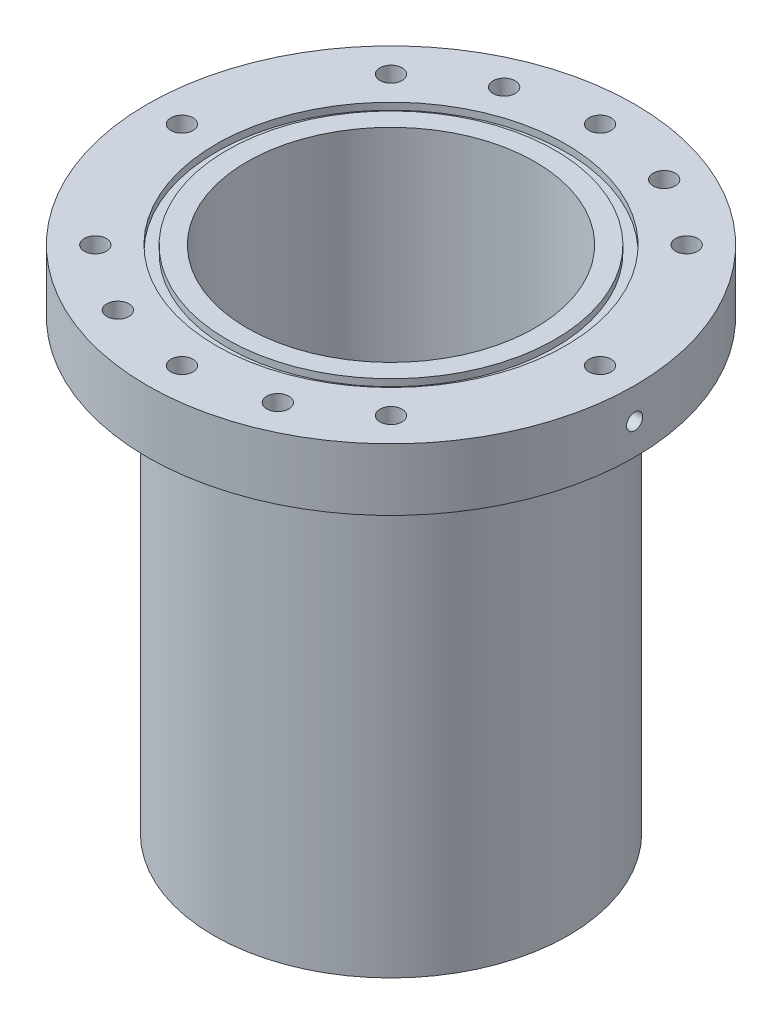
from build123d import *

# Parameters (mm, degrees)
SKETCH2_R               = 50.8
SKETCH2_R_2             = 41.275
BASE_CYLINDER_DEPTH     = 292.1
SKETCH3_R               = 69.85
SKETCH3_R_2             = 41.275
AFT_FLANGE_DEPTH        = 17.78
FORWARD_START           = -17.78
SKETCH4_R               = 69.85
SKETCH4_R_2             = 41.275
FORWARD_FLANGE_DEPTH    = 17.78
SKETCH6_R               = 50.0761
SKETCH6_R_2             = 47.0027
O_RING_SLOT_1_DEPTH     = 1.9812
O_RING_START            = -1.9812
SKETCH7_R               = 50.0761
SKETCH7_R_2             = 47.0027
O_RING_SLOT_2_DEPTH     = 1.9812
CUT_EXTRUDE4_DEPTH      = 309.351187771
CUT_EXTRUDE4_DEPTH_BACK = 309.351187771
SKETCH8_R               = 3.175
FILLET1_R               = 4.7625
SKETCH9_R               = 3.175
CUT_EXTRUDE5_DEPTH      = 7.62
CUT_EXTRUDE6_START      = -7.62
SKETCH10_R              = 3.175
CUT_EXTRUDE6_DEPTH      = 7.62
CUT_EXTRUDE7_REACH      = 303.143
SKETCH11_R              = 1.4097
CUT_EXTRUDE8_REACH      = 303.143
SKETCH12_R              = 1.4097
SKETCH13_R              = 2.3114
CUT_EXTRUDE10_DEPTH     = 6.35
CUT_EXTRUDE11_START     = -6.35
SKETCH14_R              = 2.3114
CUT_EXTRUDE11_DEPTH     = 6.35
SKETCH17_R              = 69.85
CUT_EXTRUDE12_DEPTH     = 146.05


with BuildPart() as part:
    # Sketch2 → Base Cylinder (new body)
    with BuildSketch(Plane(origin=(0, 0, 0), x_dir=(1, 0, 0), z_dir=(0, 1, 0))):
        Circle(SKETCH2_R)
        Circle(SKETCH2_R_2, mode=Mode.SUBTRACT)
    extrude(amount=BASE_CYLINDER_DEPTH)

    # Sketch3 → Aft Flange (add)
    with BuildSketch(Plane.XZ):
        Circle(SKETCH3_R)
        Circle(SKETCH3_R_2, mode=Mode.SUBTRACT)
    extrude(amount=-AFT_FLANGE_DEPTH)

    # Sketch4 → Forward Flange (add)
    with BuildSketch(Plane(origin=(0, 292.1, 0), x_dir=(1, 0, 0), z_dir=(0, 1, 0)).offset(FORWARD_START)):
        Circle(SKETCH4_R)
        Circle(SKETCH4_R_2, mode=Mode.SUBTRACT)
    extrude(amount=FORWARD_FLANGE_DEPTH)

    # Sketch6 → O-Ring Slot 1 (cut)
    with BuildSketch(Plane.XZ):
        Circle(SKETCH6_R)
        Circle(SKETCH6_R_2, mode=Mode.SUBTRACT)
    extrude(amount=-O_RING_SLOT_1_DEPTH, mode=Mode.SUBTRACT)

    # Sketch7 → O-Ring Slot 2 (cut)
    with BuildSketch(Plane(origin=(0, 292.1, 0), x_dir=(1, 0, 0), z_dir=(0, 1, 0)).offset(O_RING_START)):
        Circle(SKETCH7_R)
        Circle(SKETCH7_R_2, mode=Mode.SUBTRACT)
    extrude(amount=O_RING_SLOT_2_DEPTH, mode=Mode.SUBTRACT)

    # Sketch8 → Cut-Extrude4 (cut, two sides: drawn at the far end of the back side and taken through both)
    with BuildSketch(Plane.XZ.offset(-CUT_EXTRUDE4_DEPTH_BACK)):
        with Locations((-59.9186, 0)):
            Circle(SKETCH8_R)
        with Locations((-42.368848379, 42.368848379)):
            Circle(SKETCH8_R)
        with Locations((0, 59.9186)):
            Circle(SKETCH8_R)
        with Locations((42.368848379, 42.368848379)):
            Circle(SKETCH8_R)
        with Locations((59.9186, 0)):
            Circle(SKETCH8_R)
        with Locations((42.368848379, -42.368848379)):
            Circle(SKETCH8_R)
        with Locations((0, -59.9186)):
            Circle(SKETCH8_R)
        with Locations((-42.368848379, -42.368848379)):
            Circle(SKETCH8_R)
    extrude(amount=CUT_EXTRUDE4_DEPTH + CUT_EXTRUDE4_DEPTH_BACK, mode=Mode.SUBTRACT)

    # Fillet1
    fillet1_edges = [part.edges().sort_by_distance(p)[0] for p in [
        (-50.8, 17.78, 0),
        (-50.8, 274.32, 0),
    ]]
    fillet(fillet1_edges, radius=FILLET1_R)

    # Sketch9 → Cut-Extrude5 (cut)
    with BuildSketch(Plane(origin=(0, 292.1, 0), x_dir=(1, 0, 0), z_dir=(0, 1, 0))):
        with Locations((-22.929855511, 55.357568157)):
            Circle(SKETCH9_R)
        with Locations((22.929855511, -55.357568157)):
            Circle(SKETCH9_R)
        with Locations((22.929855511, 55.357568157)):
            Circle(SKETCH9_R)
        with Locations((-22.929855511, -55.357568157)):
            Circle(SKETCH9_R)
    extrude(amount=-CUT_EXTRUDE5_DEPTH, mode=Mode.SUBTRACT)

    # Sketch10 → Cut-Extrude6 (cut)
    with BuildSketch(Plane.XZ.offset(CUT_EXTRUDE6_START)):
        with Locations((-22.929855511, 55.357568157)):
            Circle(SKETCH10_R)
        with Locations((22.929855511, -55.357568157)):
            Circle(SKETCH10_R)
        with Locations((22.929855511, 55.357568157)):
            Circle(SKETCH10_R)
        with Locations((-22.929855511, -55.357568157)):
            Circle(SKETCH10_R)
    extrude(amount=CUT_EXTRUDE6_DEPTH, mode=Mode.SUBTRACT)

    # Sketch11 → Cut-Extrude7 (cut, up to next)
    with BuildSketch(Plane(origin=(0, 284.48, 0), x_dir=(1, 0, 0), z_dir=(0, 1, 0)), mode=Mode.PRIVATE) as cut_extrude7_sk1:
        with Locations((-22.929855511, 55.357568157)):
            Circle(SKETCH11_R)
    cut_extrude7_tool1 = extrude(cut_extrude7_sk1.sketch, amount=-CUT_EXTRUDE7_REACH, mode=Mode.PRIVATE) & part.part
    # Sketch11 → Cut-Extrude7 (cut, up to next)
    with BuildSketch(Plane(origin=(0, 284.48, 0), x_dir=(1, 0, 0), z_dir=(0, 1, 0)), mode=Mode.PRIVATE) as cut_extrude7_sk2:
        with Locations((22.929855511, 55.357568157)):
            Circle(SKETCH11_R)
    cut_extrude7_tool2 = extrude(cut_extrude7_sk2.sketch, amount=-CUT_EXTRUDE7_REACH, mode=Mode.PRIVATE) & part.part
    # Sketch11 → Cut-Extrude7 (cut, up to next)
    with BuildSketch(Plane(origin=(0, 284.48, 0), x_dir=(1, 0, 0), z_dir=(0, 1, 0)), mode=Mode.PRIVATE) as cut_extrude7_sk3:
        with Locations((-22.929855511, -55.357568157)):
            Circle(SKETCH11_R)
    cut_extrude7_tool3 = extrude(cut_extrude7_sk3.sketch, amount=-CUT_EXTRUDE7_REACH, mode=Mode.PRIVATE) & part.part
    # Sketch11 → Cut-Extrude7 (cut, up to next)
    with BuildSketch(Plane(origin=(0, 284.48, 0), x_dir=(1, 0, 0), z_dir=(0, 1, 0)), mode=Mode.PRIVATE) as cut_extrude7_sk4:
        with Locations((22.929855511, -55.357568157)):
            Circle(SKETCH11_R)
    cut_extrude7_tool4 = extrude(cut_extrude7_sk4.sketch, amount=-CUT_EXTRUDE7_REACH, mode=Mode.PRIVATE) & part.part
    add(cut_extrude7_tool1.solids().sort_by_distance((-22.929856, 284.48, -55.357568))[0], mode=Mode.SUBTRACT)
    add(cut_extrude7_tool2.solids().sort_by_distance((22.929856, 284.48, -55.357568))[0], mode=Mode.SUBTRACT)
    add(cut_extrude7_tool3.solids().sort_by_distance((-22.929856, 284.48, 55.357568))[0], mode=Mode.SUBTRACT)
    add(cut_extrude7_tool4.solids().sort_by_distance((22.929856, 284.48, 55.357568))[0], mode=Mode.SUBTRACT)

    # Sketch12 → Cut-Extrude8 (cut, up to next)
    with BuildSketch(Plane.XZ.offset(-7.62), mode=Mode.PRIVATE) as cut_extrude8_sk1:
        with Locations((-22.929855511, 55.357568157)):
            Circle(SKETCH12_R)
    cut_extrude8_tool1 = extrude(cut_extrude8_sk1.sketch, amount=-CUT_EXTRUDE8_REACH, mode=Mode.PRIVATE) & part.part
    # Sketch12 → Cut-Extrude8 (cut, up to next)
    with BuildSketch(Plane.XZ.offset(-7.62), mode=Mode.PRIVATE) as cut_extrude8_sk2:
        with Locations((22.929855511, 55.357568157)):
            Circle(SKETCH12_R)
    cut_extrude8_tool2 = extrude(cut_extrude8_sk2.sketch, amount=-CUT_EXTRUDE8_REACH, mode=Mode.PRIVATE) & part.part
    # Sketch12 → Cut-Extrude8 (cut, up to next)
    with BuildSketch(Plane.XZ.offset(-7.62), mode=Mode.PRIVATE) as cut_extrude8_sk3:
        with Locations((-22.929855511, -55.357568157)):
            Circle(SKETCH12_R)
    cut_extrude8_tool3 = extrude(cut_extrude8_sk3.sketch, amount=-CUT_EXTRUDE8_REACH, mode=Mode.PRIVATE) & part.part
    # Sketch12 → Cut-Extrude8 (cut, up to next)
    with BuildSketch(Plane.XZ.offset(-7.62), mode=Mode.PRIVATE) as cut_extrude8_sk4:
        with Locations((22.929855511, -55.357568157)):
            Circle(SKETCH12_R)
    cut_extrude8_tool4 = extrude(cut_extrude8_sk4.sketch, amount=-CUT_EXTRUDE8_REACH, mode=Mode.PRIVATE) & part.part
    add(cut_extrude8_tool1.solids().sort_by_distance((-22.929856, 7.62, 55.357568))[0], mode=Mode.SUBTRACT)
    add(cut_extrude8_tool2.solids().sort_by_distance((22.929856, 7.62, 55.357568))[0], mode=Mode.SUBTRACT)
    add(cut_extrude8_tool3.solids().sort_by_distance((-22.929856, 7.62, -55.357568))[0], mode=Mode.SUBTRACT)
    add(cut_extrude8_tool4.solids().sort_by_distance((22.929856, 7.62, -55.357568))[0], mode=Mode.SUBTRACT)

    # Sketch13 → Cut-Extrude10 (cut)
    with BuildSketch(Plane(origin=(-69.85, 0, 0), x_dir=(0, 0, -1), z_dir=(1, 0, 0))):
        with Locations((0, 283.21)):
            Circle(SKETCH13_R)
    extrude(amount=CUT_EXTRUDE10_DEPTH, mode=Mode.SUBTRACT)

    # Sketch14 → Cut-Extrude11 (cut)
    with BuildSketch(Plane(origin=(69.85, 0, 0), x_dir=(0, 0, -1), z_dir=(1, 0, 0)).offset(CUT_EXTRUDE11_START)):
        with Locations((0, 283.21)):
            Circle(SKETCH14_R)
    extrude(amount=CUT_EXTRUDE11_DEPTH, mode=Mode.SUBTRACT)

    # Sketch17 → Cut-Extrude12 (cut)
    with BuildSketch(Plane(origin=(0, 0, 0), x_dir=(-1, 0, 0), z_dir=(0, -1, 0))):
        Circle(SKETCH17_R)
    extrude(amount=-CUT_EXTRUDE12_DEPTH, mode=Mode.SUBTRACT)


solid = part.part
